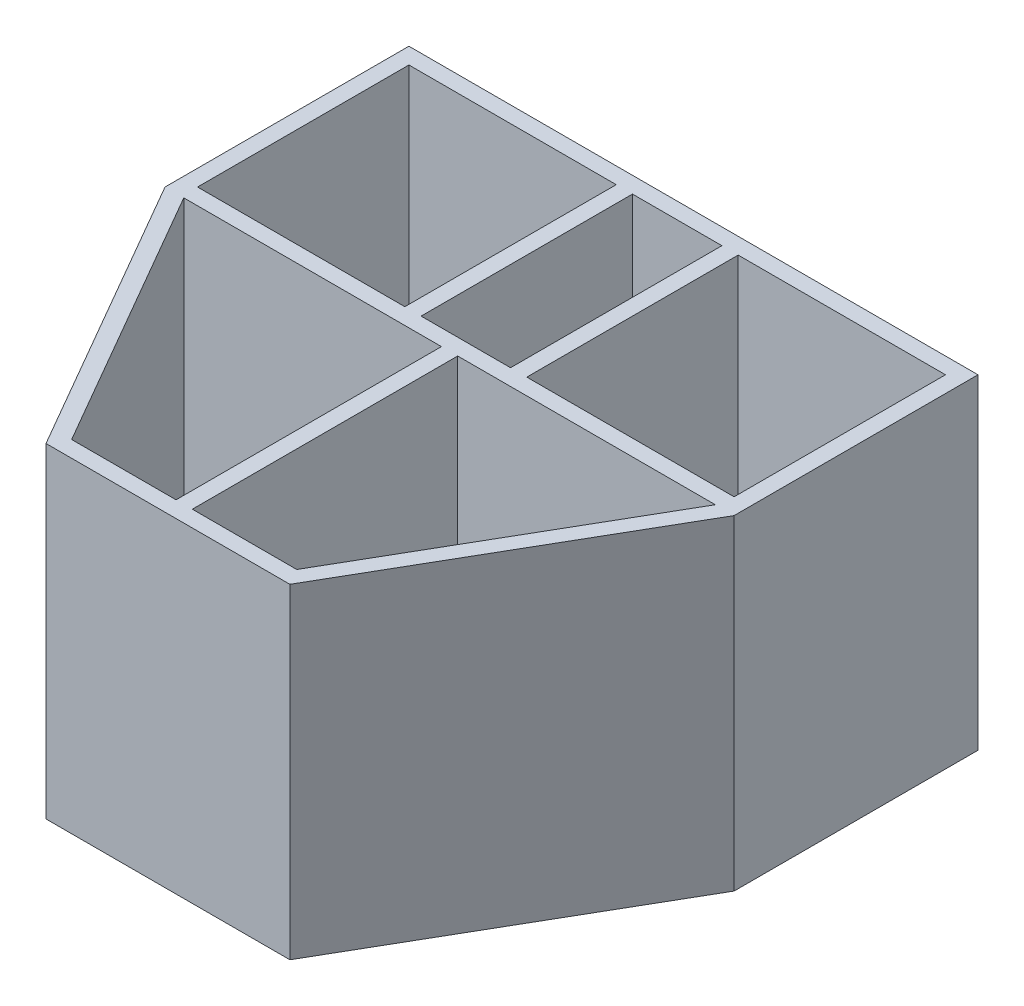
from build123d import *

# Parameters (mm, degrees)
SFIVEBASETP1_W     = 12.75
SFIVEBASETP1_H     = 13
SFIVEBASETP1_W_2   = 5.5
FFIVEBASETP1_DEPTH = 20


with BuildPart() as part:
    # SFiveBaseTP1 → FFiveBaseTP1 (new body)
    with BuildSketch(Plane(origin=(0, 0, 0), x_dir=(1, 0, 0), z_dir=(0, 1, 0))):
        Polygon((-17.5, 15), (17.5, 15), (17.5, 0), (7.5, -17.320508076), (-7.5, -17.320508076), (-17.5, 0), align=None)
        Polygon((-16.345299462, 0), (-6.922649731, -16.320508076), (-0.5, -16.320508076), (-0.5, 0), align=None, mode=Mode.SUBTRACT)
        with Locations((-10.125, 7.5)):
            Rectangle(SFIVEBASETP1_W, SFIVEBASETP1_H, mode=Mode.SUBTRACT)
        with Locations((10.125, 7.5)):
            Rectangle(SFIVEBASETP1_W, SFIVEBASETP1_H, mode=Mode.SUBTRACT)
        Polygon((0.5, 0), (0.5, -16.320508076), (6.922649731, -16.320508076), (16.345299462, 0), align=None, mode=Mode.SUBTRACT)
        with Locations((0, 7.5)):
            Rectangle(SFIVEBASETP1_W_2, SFIVEBASETP1_H, mode=Mode.SUBTRACT)
    extrude(amount=FFIVEBASETP1_DEPTH)


solid = part.part
